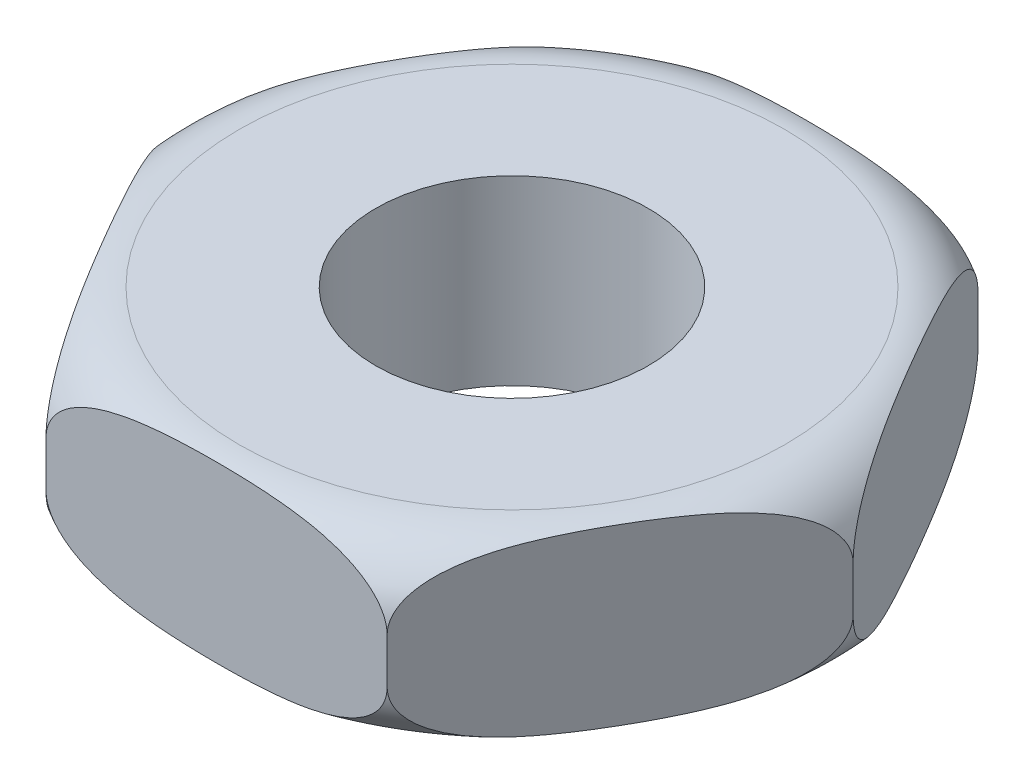
from build123d import *

# Parameters (mm, degrees)
SKETCH1_R           = 6
BOSS_EXTRUDE1_DEPTH = 4


with BuildPart() as part:
    # Sketch1 → Boss-Extrude1 (new body, symmetric)
    with BuildSketch(Plane(origin=(0, 0, 0), x_dir=(1, 0, 0), z_dir=(0, 1, 0))):
        Polygon((15.011106999, 0), (7.505553499, 13), (-7.505553499, 13), (-15.011106999, 0), (-7.505553499, -13), (7.505553499, -13), align=None)
        Circle(SKETCH1_R, mode=Mode.SUBTRACT)
    extrude(amount=BOSS_EXTRUDE1_DEPTH, both=True)

    # Sketch2 → Cut-Revolve1 (revolve, cut)
    with BuildSketch(Plane.XY):
        with BuildLine():
            Line((15.011106999, 4), (15.011106999, 1))
            ThreePointArc((15.011106999, 1), (14.132427342, 3.121320344), (12.011106999, 4))
            Line((12.011106999, 4), (15.011106999, 4))
        make_face()
    cut_revolve1 = revolve(axis=Axis((0, 0, 0), (0, -1, 0)), mode=Mode.SUBTRACT)

    # Mirror1: Cut-Revolve1 across plane
    add(cut_revolve1.mirror(Plane.ZX), mode=Mode.SUBTRACT)


solid = part.part
